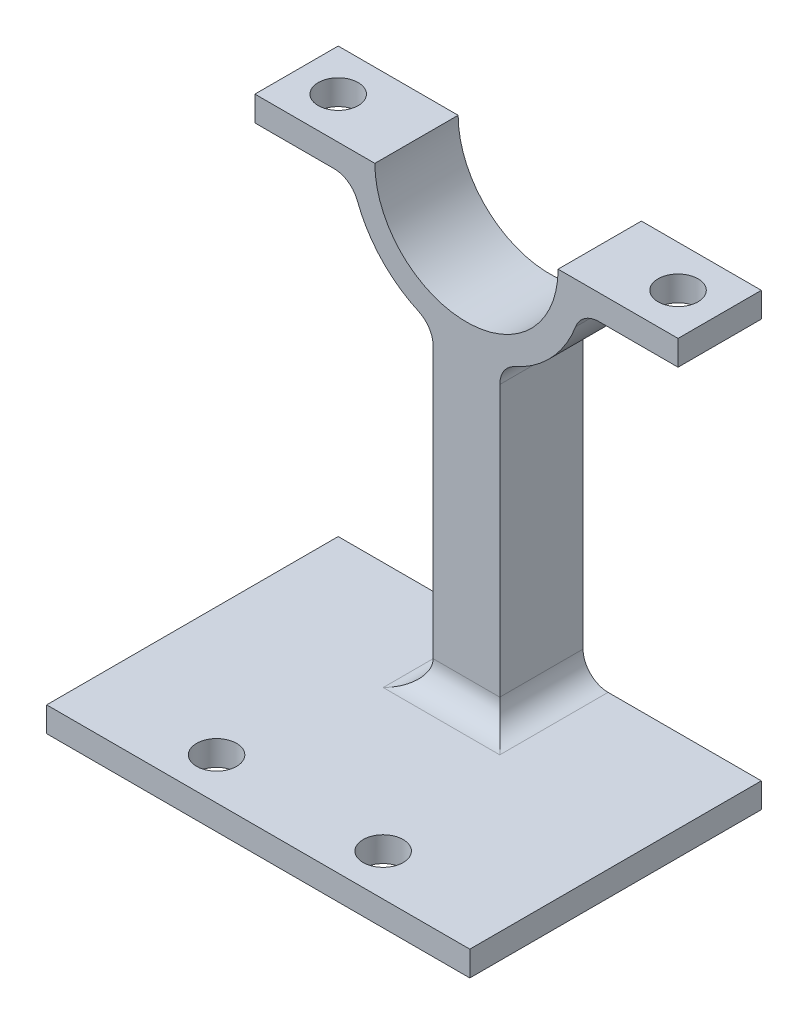
from build123d import *

# Parameters (mm, degrees)
BOSS_EXTRUDE1_DEPTH = 2.5
SKETCH2_R           = 1.2
CUT_EXTRUDE1_DEPTH  = 8
BOSS_EXTRUDE2_START = -25.5
SKETCH6_W           = 4
SKETCH6_H           = 5
BOSS_EXTRUDE2_DEPTH = 18.791796
SKETCH7_W           = 25.4
SKETCH7_H           = 17.5
BOSS_EXTRUDE4_DEPTH = 1.5
FILLET1_R           = 1.5
SKETCH8_R           = 1.2
CUT_EXTRUDE3_DEPTH  = 28


with BuildPart() as part:
    # Sketch1 → Boss-Extrude1 (new body, symmetric)
    with BuildSketch(Plane.XY):
        with BuildLine():
            Line((5.5, 0), (12.7, 0))
            Line((12.7, 0), (12.7, -1.5))
            Line((12.7, -1.5), (6.837397166, -1.5))
            ThreePointArc((6.837397166, -1.5), (0, -7), (-6.837397166, -1.5))
            Line((-6.837397166, -1.5), (-12.7, -1.5))
            Line((-12.7, -1.5), (-12.7, 0))
            Line((-12.7, 0), (-5.5, 0))
            ThreePointArc((-5.5, 0), (0, -5.5), (5.5, 0))
        make_face()
    extrude(amount=BOSS_EXTRUDE1_DEPTH, both=True)

    # Sketch2 → Cut-Extrude1 (cut, through all)
    with BuildSketch(Plane(origin=(0, 0, 0), x_dir=(1, 0, 0), z_dir=(0, 1, 0))):
        with Locations((-10.2, 0)):
            Circle(SKETCH2_R)
        with Locations((10.2, 0)):
            Circle(SKETCH2_R)
    extrude(amount=-CUT_EXTRUDE1_DEPTH, mode=Mode.SUBTRACT)

    # Sketch6 → Boss-Extrude2 (add)
    with BuildSketch(Plane(origin=(0, 0, 0), x_dir=(1, 0, 0), z_dir=(0, 1, 0)).offset(BOSS_EXTRUDE2_START)):
        Rectangle(SKETCH6_W, SKETCH6_H)
    extrude(amount=BOSS_EXTRUDE2_DEPTH)

    # Sketch7 → Boss-Extrude4 (add)
    with BuildSketch(Plane.XZ.offset(25.5)):
        with Locations((0, 6.25)):
            Rectangle(SKETCH7_W, SKETCH7_H)
    extrude(amount=BOSS_EXTRUDE4_DEPTH)

    # Fillet1
    fillet1_edges = [part.edges().sort_by_distance(p)[0] for p in [
        (6.837397166, -1.5, 0),
        (-6.837397166, -1.5, 0),
        (-2, -25.5, 0),
        (0, -25.5, 2.5),
        (2, -25.5, 0),
        (-2, -6.708204, 0),
        (2, -6.708204, 0),
    ]]
    fillet(fillet1_edges, radius=FILLET1_R)

    # Sketch8 → Cut-Extrude3 (cut, through all)
    with BuildSketch(Plane(origin=(0, 0, 0), x_dir=(1, 0, 0), z_dir=(0, 1, 0))):
        with Locations((-5, -12.5)):
            Circle(SKETCH8_R)
        with Locations((5, -12.5)):
            Circle(SKETCH8_R)
    extrude(amount=-CUT_EXTRUDE3_DEPTH, mode=Mode.SUBTRACT)


solid = part.part
